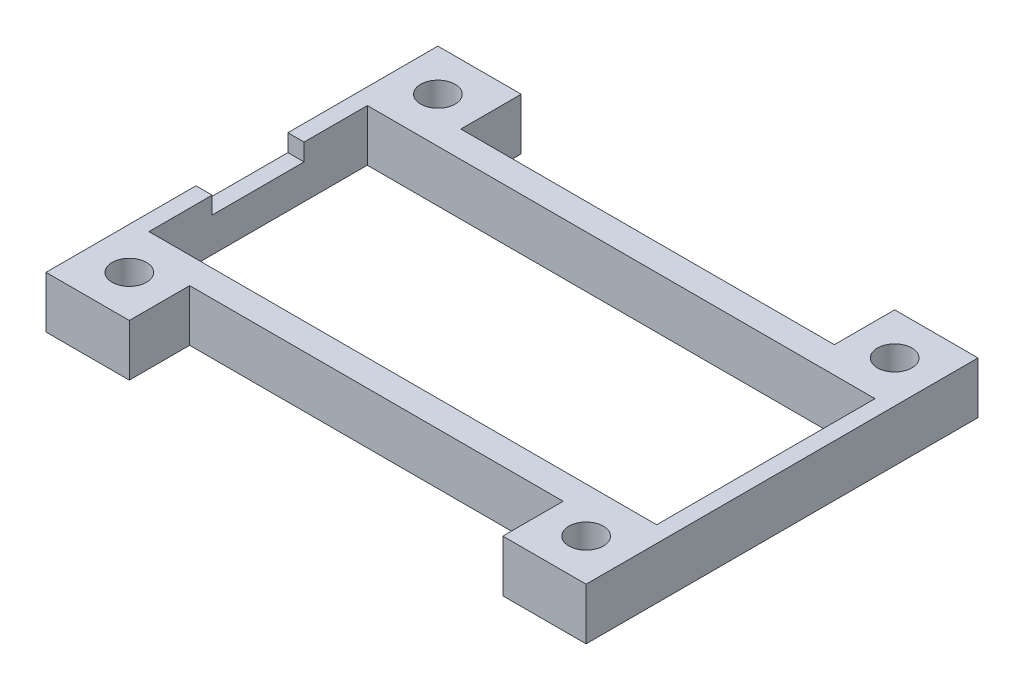
from build123d import *

# Parameters (mm, degrees)
SKETCH1_W           = 47
SKETCH1_H           = 23.6
SKETCH1_W_2         = 44.18
SKETCH1_H_2         = 19
BOSS_EXTRUDE1_DEPTH = 4.5
SKETCH6_W           = 7.25
SKETCH6_H           = 4.5
BOSS_EXTRUDE3_DEPTH = 5.25
SKETCH7_W           = 7.25
SKETCH7_H           = 4.5
BOSS_EXTRUDE4_DEPTH = 5.25
SKETCH8_R           = 1.5
CUT_EXTRUDE2_DEPTH  = 5.5
SKETCH10_W          = 1.41
SKETCH10_H          = 8
CUT_EXTRUDE3_DEPTH  = 1.5


with BuildPart() as part:
    # Sketch1 → Boss-Extrude1 (new body)
    with BuildSketch(Plane(origin=(0, 0, 0), x_dir=(1, 0, 0), z_dir=(0, 1, 0))):
        with Locations((22.09, 9.5)):
            Rectangle(SKETCH1_W, SKETCH1_H)
        with Locations((22.09, 9.5)):
            Rectangle(SKETCH1_W_2, SKETCH1_H_2, mode=Mode.SUBTRACT)
    extrude(amount=BOSS_EXTRUDE1_DEPTH)

    # Sketch6 → Boss-Extrude3 (add)
    with BuildSketch(Plane.XY.offset(2.3)):
        with Locations((2.215, 2.25)):
            Rectangle(SKETCH6_W, SKETCH6_H)
        with Locations((41.965, 2.25)):
            Rectangle(SKETCH6_W, SKETCH6_H)
    extrude(amount=BOSS_EXTRUDE3_DEPTH)

    # Sketch7 → Boss-Extrude4 (add)
    with BuildSketch(Plane(origin=(0, 0, -21.3), x_dir=(-1, 0, 0), z_dir=(0, 0, -1))):
        with Locations((-41.965, 2.25)):
            Rectangle(SKETCH7_W, SKETCH7_H)
        with Locations((-2.215, 2.25)):
            Rectangle(SKETCH7_W, SKETCH7_H)
    extrude(amount=BOSS_EXTRUDE4_DEPTH)

    # Sketch8 → Cut-Extrude2 (cut, through all)
    with BuildSketch(Plane(origin=(0, 4.5, 0), x_dir=(1, 0, 0), z_dir=(0, 1, 0))):
        with Locations((41.965, 22.925)):
            Circle(SKETCH8_R)
        with Locations((41.965, -3.925)):
            Circle(SKETCH8_R)
        with Locations((2.215, -3.925)):
            Circle(SKETCH8_R)
        with Locations((2.215, 22.925)):
            Circle(SKETCH8_R)
    extrude(amount=-CUT_EXTRUDE2_DEPTH, mode=Mode.SUBTRACT)

    # Sketch10 → Cut-Extrude3 (cut)
    with BuildSketch(Plane(origin=(0, 4.5, 0), x_dir=(1, 0, 0), z_dir=(0, 1, 0))):
        with Locations((-0.705, 9.5)):
            Rectangle(SKETCH10_W, SKETCH10_H)
    extrude(amount=-CUT_EXTRUDE3_DEPTH, mode=Mode.SUBTRACT)


solid = part.part
